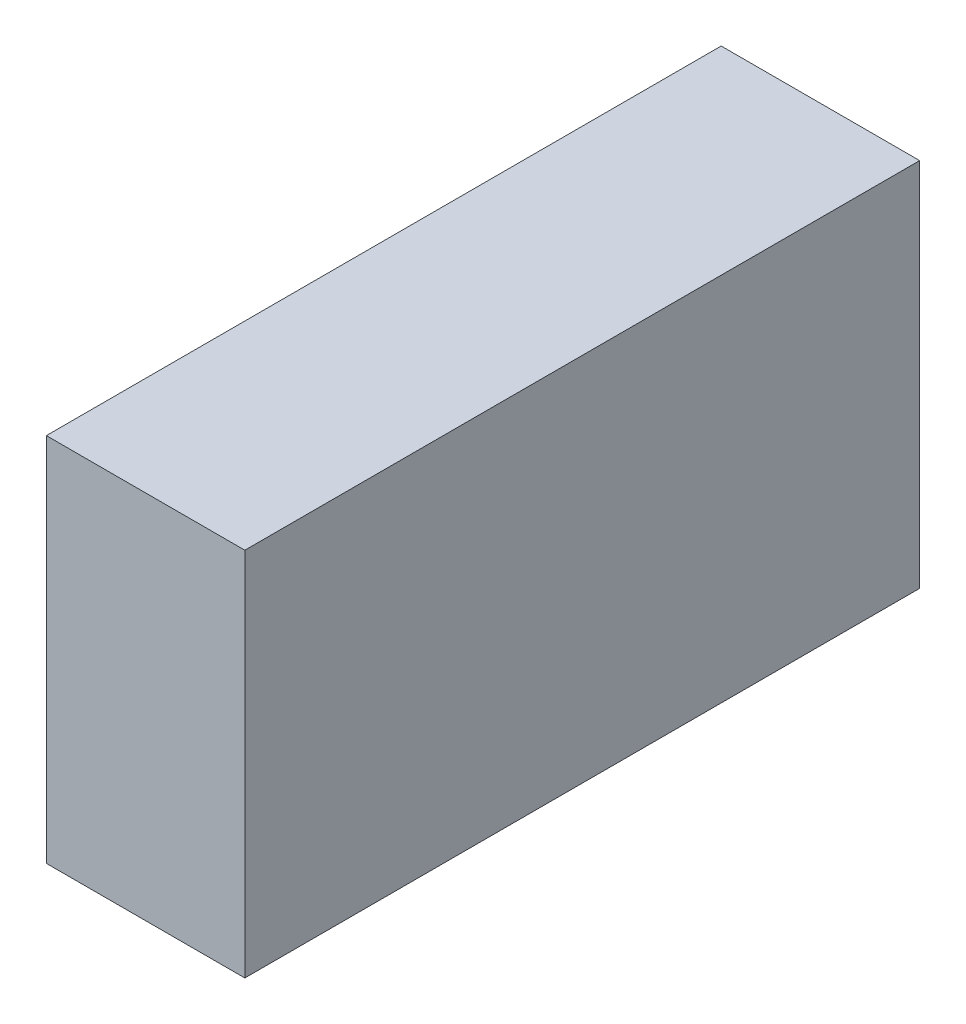
from build123d import *

# Parameters (mm, degrees)
SKETCH1_W           = 15
SKETCH1_H           = 51
BOSS_EXTRUDE1_DEPTH = 28


with BuildPart() as part:
    # Sketch1 → Boss-Extrude1 (new body)
    with BuildSketch(Plane(origin=(0, 0, 0), x_dir=(1, 0, 0), z_dir=(0, 1, 0))):
        Rectangle(SKETCH1_W, SKETCH1_H)
    extrude(amount=BOSS_EXTRUDE1_DEPTH)


solid = part.part
